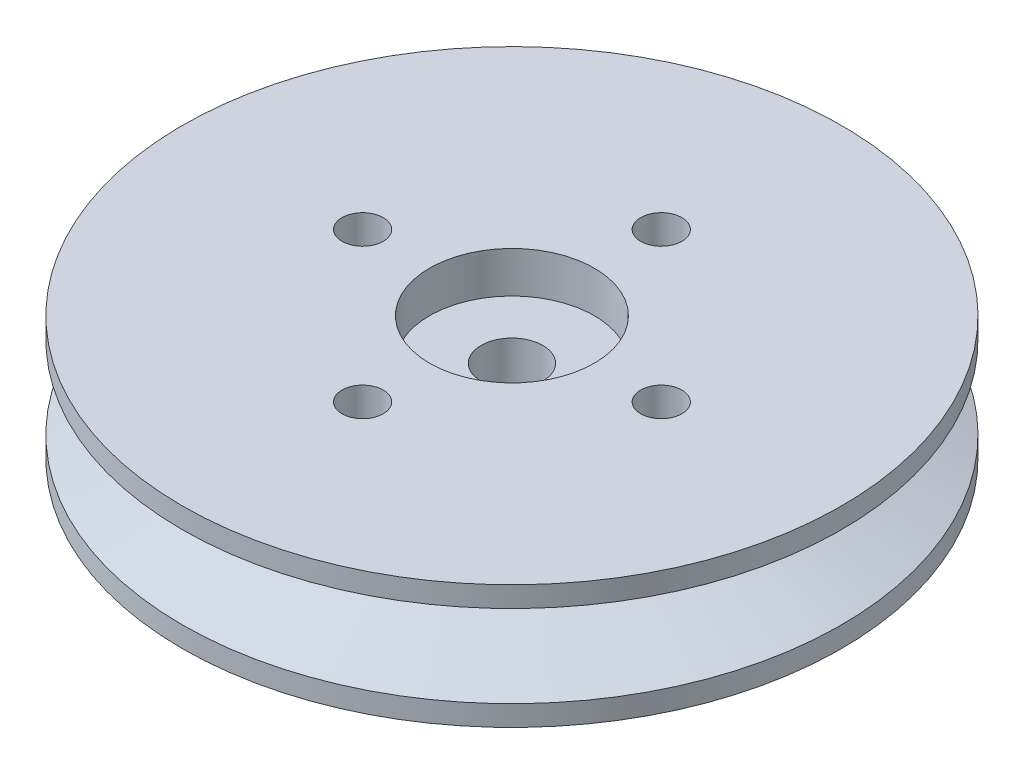
from build123d import *

# Parameters (mm, degrees)
SKETCH1_R           = 16
SKETCH1_R_2         = 1
SKETCH1_R_3         = 1.5
BOSS_EXTRUDE1_DEPTH = 6
SKETCH2_R           = 4
CUT_EXTRUDE1_DEPTH  = 2


with BuildPart() as part:
    # Sketch1 → Boss-Extrude1 (new body)
    with BuildSketch(Plane(origin=(0, 0, 0), x_dir=(1, 0, 0), z_dir=(0, 1, 0))):
        Circle(SKETCH1_R)
        with Locations((0, 7.25)):
            Circle(SKETCH1_R_2, mode=Mode.SUBTRACT)
        with Locations((7.25, 0)):
            Circle(SKETCH1_R_2, mode=Mode.SUBTRACT)
        with Locations((0, -7.25)):
            Circle(SKETCH1_R_2, mode=Mode.SUBTRACT)
        with Locations((-7.25, 0)):
            Circle(SKETCH1_R_2, mode=Mode.SUBTRACT)
        Circle(SKETCH1_R_3, mode=Mode.SUBTRACT)
    extrude(amount=BOSS_EXTRUDE1_DEPTH)

    # Sketch2 → Cut-Extrude1 (cut)
    with BuildSketch(Plane(origin=(0, 6, 0), x_dir=(1, 0, 0), z_dir=(0, 1, 0))):
        Circle(SKETCH2_R)
    extrude(amount=-CUT_EXTRUDE1_DEPTH, mode=Mode.SUBTRACT)

    # Sketch3 → Cut-Revolve1 (revolve, cut)
    with BuildSketch(Plane(origin=(0, 0, 0), x_dir=(0, 0, -1), z_dir=(1, 0, 0))):
        Polygon((-16, 5), (-12, 3.5), (-12, 2.5), (-16, 1), align=None)
    revolve(axis=Axis((0, 6, 0), (0, -1, 0)), mode=Mode.SUBTRACT)


solid = part.part
